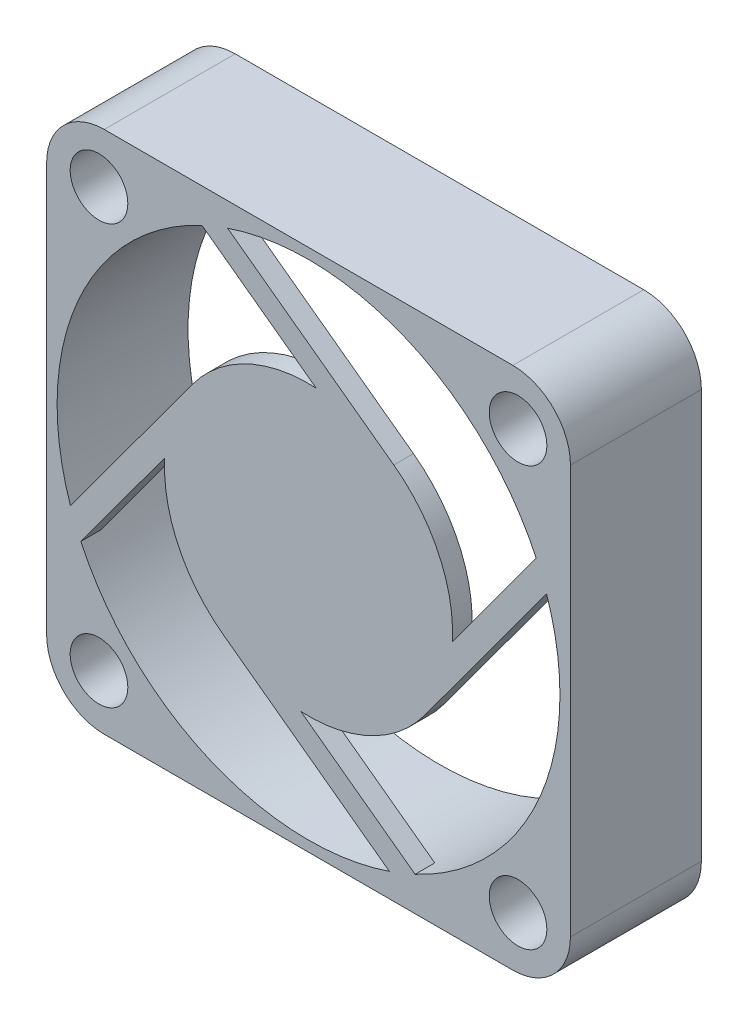
from build123d import *

# Parameters (mm, degrees)
SKETCH1_W           = 40
SKETCH1_H           = 40
BOSS_EXTRUDE1_DEPTH = 10
SKETCH2_R           = 2.2
CUT_EXTRUDE1_DEPTH  = 10
SKETCH3_R           = 19.2
CUT_EXTRUDE2_DEPTH  = 10
FILLET1_R           = 4.4
BOSS_EXTRUDE2_DEPTH = 1.5


with BuildPart() as part:
    # Sketch1 → Boss-Extrude1 (new body)
    with BuildSketch(Plane.XY):
        Rectangle(SKETCH1_W, SKETCH1_H)
    extrude(amount=BOSS_EXTRUDE1_DEPTH)

    # Sketch2 → Cut-Extrude1 (cut)
    with BuildSketch(Plane.XY.offset(10)):
        with Locations((-16, 16)):
            Circle(SKETCH2_R)
        with Locations((16, 16)):
            Circle(SKETCH2_R)
        with Locations((16, -16)):
            Circle(SKETCH2_R)
        with Locations((-16, -16)):
            Circle(SKETCH2_R)
    extrude(amount=-CUT_EXTRUDE1_DEPTH, mode=Mode.SUBTRACT)

    # Sketch3 → Cut-Extrude2 (cut)
    with BuildSketch(Plane.XY.offset(10)):
        Circle(SKETCH3_R)
    extrude(amount=-CUT_EXTRUDE2_DEPTH, mode=Mode.SUBTRACT)

    # Fillet1
    fillet1_edges = [part.edges().sort_by_distance(p)[0] for p in [
        (-20, 20, 5),
        (20, 20, 5),
        (20, -20, 5),
        (-20, -20, 5),
    ]]
    fillet(fillet1_edges, radius=FILLET1_R)

    # Sketch4 → Boss-Extrude2 (add)
    with BuildSketch(Plane.XY.offset(10)):
        with BuildLine():
            Line((6.50980229, 8.866931496), (-6.175215064, 18.179843754))
            ThreePointArc((-6.175215064, 18.179843754), (-7.1684264, 17.811615956), (-8.139818596, 17.389173449))
            Line((-8.139818596, 17.389173449), (0.583931442, 10.98449016))
            ThreePointArc((0.583931442, 10.98449016), (-4.707199842, 9.941944963), (-8.866931496, 6.50980229))
            Line((-8.866931496, 6.50980229), (-18.179843754, -6.175215064))
            ThreePointArc((-18.179843754, -6.175215064), (-17.811615956, -7.1684264), (-17.389173449, -8.139818596))
            Line((-17.389173449, -8.139818596), (-10.98449016, 0.583931442))
            ThreePointArc((-10.98449016, 0.583931442), (-9.941944963, -4.707199842), (-6.50980229, -8.866931496))
            Line((-6.50980229, -8.866931496), (6.175215064, -18.179843754))
            ThreePointArc((6.175215064, -18.179843754), (7.1684264, -17.811615956), (8.139818596, -17.389173449))
            Line((8.139818596, -17.389173449), (-0.583931442, -10.98449016))
            ThreePointArc((-0.583931442, -10.98449016), (4.707199842, -9.941944963), (8.866931496, -6.50980229))
            Line((8.866931496, -6.50980229), (18.179843754, 6.175215064))
            ThreePointArc((18.179843754, 6.175215064), (17.811615956, 7.1684264), (17.389173449, 8.139818596))
            Line((17.389173449, 8.139818596), (10.98449016, -0.583931442))
            ThreePointArc((10.98449016, -0.583931442), (9.941944963, 4.707199842), (6.50980229, 8.866931496))
        make_face()
    extrude(amount=-BOSS_EXTRUDE2_DEPTH)


solid = part.part
